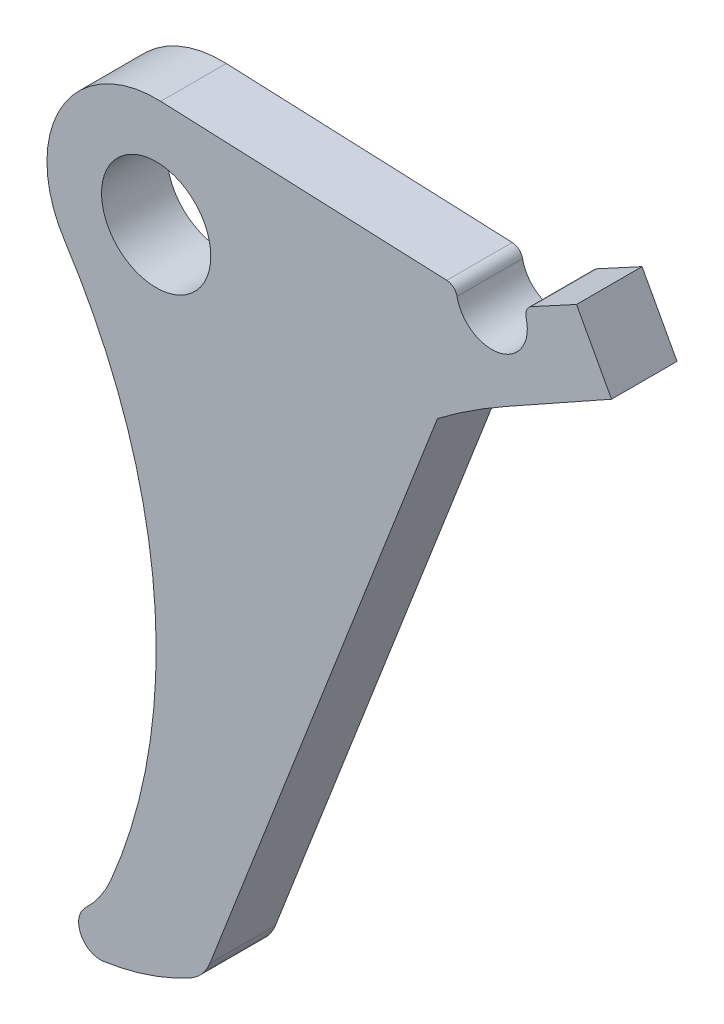
from build123d import *

# Parameters (mm, degrees)
SKETCH_1_R      = 5
EXTRUDE_1_DEPTH = 3


with BuildPart() as part:
    # Эскиз1 → Бобышка-Вытянуть1 (new body, symmetric)
    with BuildSketch(Plane.XY):
        with BuildLine():
            Line((4.916234413, -56.120413603), (25.760048074, -2.486528587))
            ThreePointArc((25.760048074, -2.486528587), (28.806805421, -0.347478176), (31.992021255, 1.579350067))
            Line((31.992021255, 1.579350067), (41.693220111, 7.005736507))
            Line((41.693220111, 7.005736507), (38.489887361, 12.920302494))
            Line((38.489887361, 12.920302494), (34.365244293, 10.68639315))
            ThreePointArc((34.365244293, 10.68639315), (33.923481874, 10.203655675), (33.874797711, 9.55110732))
            ThreePointArc((33.874797711, 9.55110732), (31.465191403, 5.552741192), (27.545035778, 8.087600975))
            ThreePointArc((27.545035778, 8.087600975), (27.214853309, 8.652551452), (26.606025774, 8.892381677))
            Line((26.606025774, 8.892381677), (0.41924208, 9.991207939))
            ThreePointArc((0.41924208, 9.991207939), (-8.687811377, 4.951962588), (-8.383148839, -5.451863492))
            ThreePointArc((-8.383148839, -5.451863492), (-0.194512316, -29.232087684), (-4.16010245, -54.068088281))
            ThreePointArc((-4.16010245, -54.068088281), (-5.14748476, -55.852284698), (-6.476272813, -57.39908882))
            ThreePointArc((-6.476272813, -57.39908882), (-6.89807893, -59.725920701), (-4.806109838, -60.82852322))
            ThreePointArc((-4.806109838, -60.82852322), (-0.738045269, -59.854283225), (3.097962953, -58.185950579))
            ThreePointArc((3.097962953, -58.185950579), (4.190313841, -57.314464556), (4.916234413, -56.120413603))
        make_face()
        Circle(SKETCH_1_R, mode=Mode.SUBTRACT)
    extrude(amount=EXTRUDE_1_DEPTH, both=True)


solid = part.part
